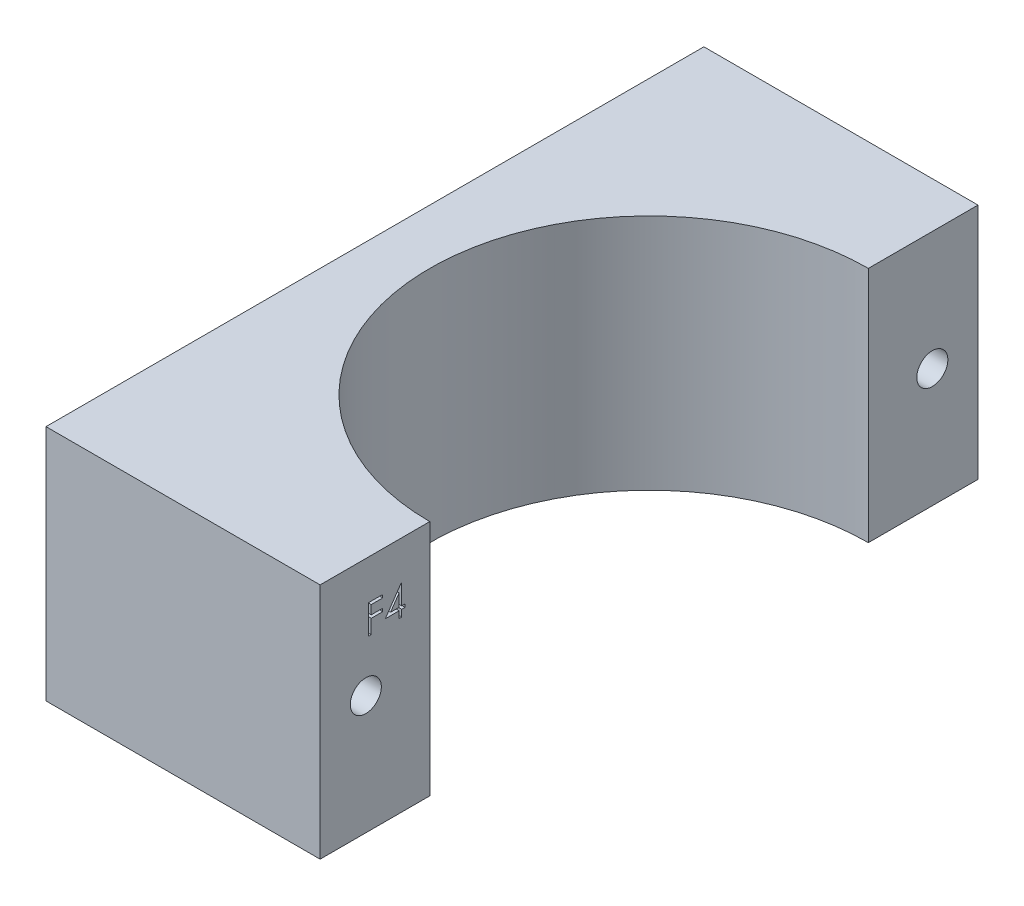
from build123d import *

# Parameters (mm, degrees)
BOSS_EXTRUDE1_DEPTH = 26
SKETCH2_R           = 1.7
CUT_EXTRUDE1_DEPTH  = 31
CUT_EXTRUDE2_DEPTH  = 1


with BuildPart() as part:
    # Sketch1 → Boss-Extrude1 (new body)
    with BuildSketch(Plane(origin=(0, 0, 0), x_dir=(1, 0, 0), z_dir=(0, 1, 0))):
        with BuildLine():
            Line((-46.998275301, 32.528571429), (-46.998275301, -39.471428571))
            Line((-46.998275301, -39.471428571), (-16.998275301, -39.471428571))
            Line((-16.998275301, -39.471428571), (-16.998275301, -27.471428571))
            ThreePointArc((-16.998275301, -27.471428571), (-40.998275301, -3.471428571), (-16.998275301, 20.528571429))
            Line((-16.998275301, 20.528571429), (-16.998275301, 32.528571429))
            Line((-16.998275301, 32.528571429), (-46.998275301, 32.528571429))
        make_face()
    extrude(amount=BOSS_EXTRUDE1_DEPTH)

    # Sketch2 → Cut-Extrude1 (cut, through all)
    with BuildSketch(Plane(origin=(-16.998275301, 0, 0), x_dir=(0, 0, -1), z_dir=(1, 0, 0))):
        with Locations((-34.471428571, 13)):
            Circle(SKETCH2_R)
        with Locations((27.528571429, 13)):
            Circle(SKETCH2_R)
    extrude(amount=-CUT_EXTRUDE1_DEPTH, mode=Mode.SUBTRACT)

    # Sketch3 → Cut-Extrude2 (cut)
    with BuildSketch(Plane(origin=(-16.998275301, 0, 0), x_dir=(0, 0, -1), z_dir=(1, 0, 0))):
        Polygon((-34.164231178, 21.664809495), (-32.617436306, 21.664809495), (-32.617436306, 21.33916847), (-33.87929528, 21.33916847), (-33.87929528, 20.362245393), (-32.617436306, 20.362245393), (-32.617436306, 20.036604367), (-33.87929528, 20.036604367), (-33.87929528, 18.489809495), (-34.164231178, 18.489809495), align=None)
        Polygon((-30.599352372, 21.746219752), (-30.541474768, 21.746219752), (-30.541474768, 19.548142829), (-30.175128614, 19.548142829), (-30.175128614, 19.222501803), (-30.541474768, 19.222501803), (-30.541474768, 18.489809495), (-30.826410665, 18.489809495), (-30.826410665, 19.222501803), (-32.332500409, 19.222501803), align=None)
        Polygon((-30.826410665, 19.548142829), (-30.826410665, 20.925757011), (-31.772168878, 19.548142829), align=None, mode=Mode.SUBTRACT)
    extrude(amount=-CUT_EXTRUDE2_DEPTH, mode=Mode.SUBTRACT)


solid = part.part
